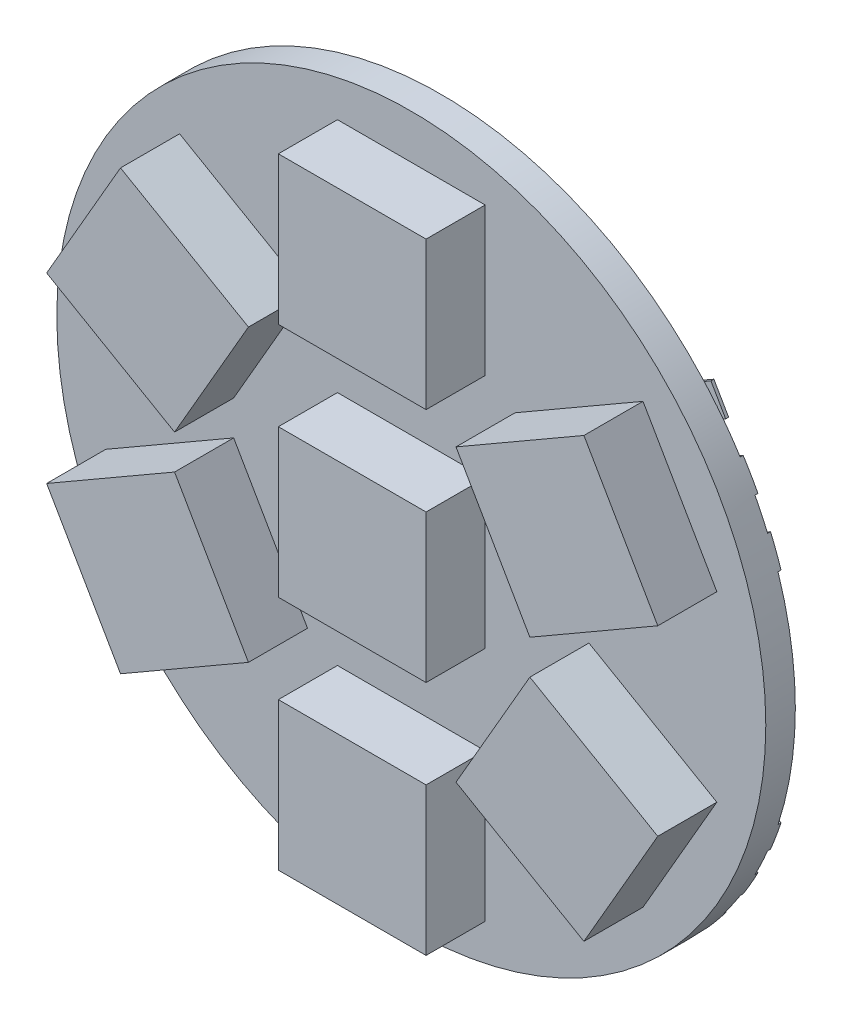
from build123d import *

# Parameters (mm, degrees)
CROQUIS1_R              = 12
SALIENTE_EXTRUIR1_DEPTH = 1
CROQUIS2_W              = 5
CROQUIS2_H              = 5
SALIENTE_EXTRUIR2_DEPTH = 2
SALIENTE_EXTRUIR3_DEPTH = 0.1


with BuildPart() as part:
    # Croquis1 → Saliente-Extruir1 (new body)
    with BuildSketch(Plane.XY):
        Circle(CROQUIS1_R)
    extrude(amount=SALIENTE_EXTRUIR1_DEPTH)

    # Croquis2 → Saliente-Extruir2 (add)
    with BuildSketch(Plane.XY.offset(1)):
        Rectangle(CROQUIS2_W, CROQUIS2_H)
        with Locations((0, -8)):
            Rectangle(CROQUIS2_W, CROQUIS2_H)
        with Locations((0, 8)):
            Rectangle(CROQUIS2_W, CROQUIS2_H)
        Polygon((-7.84326674, 7.415063509), (-10.34326674, 3.084936491), (-6.013139721, 0.584936491), (-3.513139721, 4.915063509), align=None)
        Polygon((-6.013139721, -0.584936491), (-10.34326674, -3.084936491), (-7.84326674, -7.415063509), (-3.513139721, -4.915063509), align=None)
        Polygon((6.013139721, -0.584936491), (3.513139721, -4.915063509), (7.84326674, -7.415063509), (10.34326674, -3.084936491), align=None)
        Polygon((7.84326674, 7.415063509), (3.513139721, 4.915063509), (6.013139721, 0.584936491), (10.34326674, 3.084936491), align=None)
    extrude(amount=SALIENTE_EXTRUIR2_DEPTH)

    # Croquis3 → Saliente-Extruir3 (add)
    with BuildSketch(Plane(origin=(0, 0, 0), x_dir=(-1, 0, 0), z_dir=(0, 0, -1))):
        with BuildLine():
            ThreePointArc((-9.560795314, -7.251978556), (-9.245794779, -7.649528018), (-8.914275675, -8.033410807))
            Line((-8.914275675, -8.033410807), (-5.67820323, -6.165063509))
            Line((-5.67820323, -6.165063509), (-6.17820323, -5.299038106))
            Line((-6.17820323, -5.299038106), (-9.560795314, -7.251978556))
        make_face()
        with BuildLine():
            Line((-7.17820323, -3.566987298), (-10.633279829, -5.561776702))
            ThreePointArc((-10.633279829, -5.561776702), (-10.515075861, -5.78214317), (-10.392305608, -5.999998679))
            ThreePointArc((-10.392305608, -5.999998679), (-10.265021594, -6.215249929), (-10.133279829, -6.427802106))
            Line((-10.133279829, -6.427802106), (-6.67820323, -4.433012702))
            Line((-6.67820323, -4.433012702), (-7.17820323, -3.566987298))
        make_face()
        with BuildLine():
            Line((-8.17820323, -1.834936491), (-11.414275675, -3.703283788))
            ThreePointArc((-11.414275675, -3.703283788), (-11.24758298, -4.182329148), (-11.060795314, -4.653902344))
            Line((-11.060795314, -4.653902344), (-7.67820323, -2.700961894))
            Line((-7.67820323, -2.700961894), (-8.17820323, -1.834936491))
        make_face()
        with BuildLine():
            Line((-7.67820323, 2.700961894), (-11.060795314, 4.653902344))
            ThreePointArc((-11.060795314, 4.653902344), (-11.24758298, 4.182329148), (-11.414275675, 3.703283788))
            Line((-11.414275675, 3.703283788), (-8.17820323, 1.834936491))
            Line((-8.17820323, 1.834936491), (-7.67820323, 2.700961894))
        make_face()
        with BuildLine():
            ThreePointArc((-10.133279829, 6.427802106), (-10.265021594, 6.215249929), (-10.392305608, 5.999998679))
            ThreePointArc((-10.392305608, 5.999998679), (-10.515075861, 5.78214317), (-10.633279829, 5.561776702))
            Line((-10.633279829, 5.561776702), (-7.17820323, 3.566987298))
            Line((-7.17820323, 3.566987298), (-6.67820323, 4.433012702))
            Line((-6.67820323, 4.433012702), (-10.133279829, 6.427802106))
        make_face()
        Polygon((-9.642304845, 7.299038106), (-6.17820323, 5.299038106), (-5.67820323, 6.165063509), (-9.142304845, 8.165063509), align=None)
    extrude(amount=SALIENTE_EXTRUIR3_DEPTH)


solid = part.part
